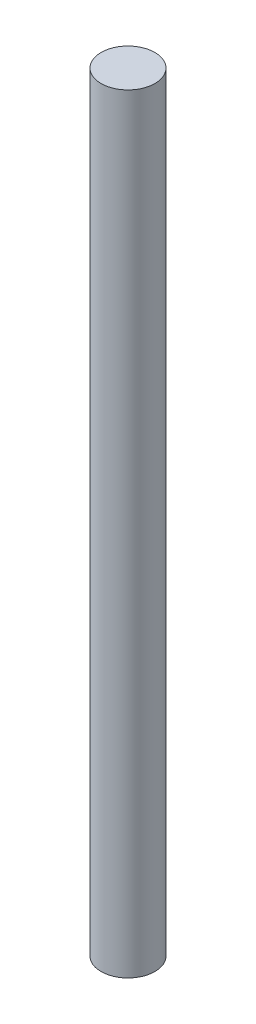
from build123d import *

# Parameters (mm, degrees)
SKETCH1_W = 1.4
SKETCH1_H = 40


with BuildPart() as part:
    # Sketch1 → Revolve1 (revolve)
    with BuildSketch(Plane.XY):
        Rectangle(SKETCH1_W, SKETCH1_H)
    revolve(axis=Axis((0.7, 20, 0), (0, -1, 0)))


solid = part.part
